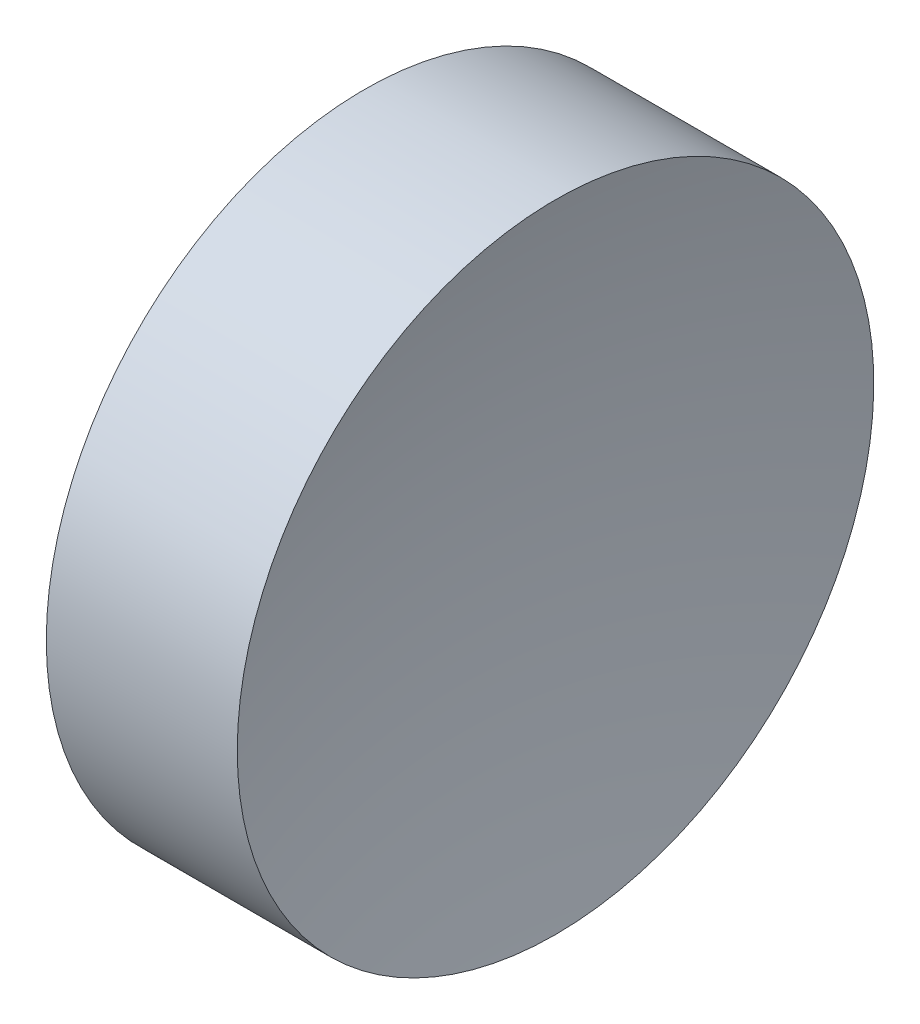
from build123d import *


with BuildPart() as part:
    # 草图1 → 旋转1 (revolve)
    with BuildSketch(Plane.XY, mode=Mode.PRIVATE) as revolve_1_sk:
        with BuildLine():
            Line((22.172189475, 13.044520575), (22.172189475, 16.194520575))
            Line((22.172189475, 16.194520575), (24.062189475, 16.194520575))
            ThreePointArc((24.062189475, 16.194520575), (23.770060278, 14.631546094), (23.672189475, 13.044520575))
            Line((23.672189475, 13.044520575), (22.172189475, 13.044520575))
        make_face()
    revolve(revolve_1_sk.sketch.rotate(Axis((21.224930557, 13.044520575, 0), (1, 0, 0)), 180), axis=Axis((21.224930557, 13.044520575, 0), (1, 0, 0)))  # turned: the seam where the file's is


solid = part.part
